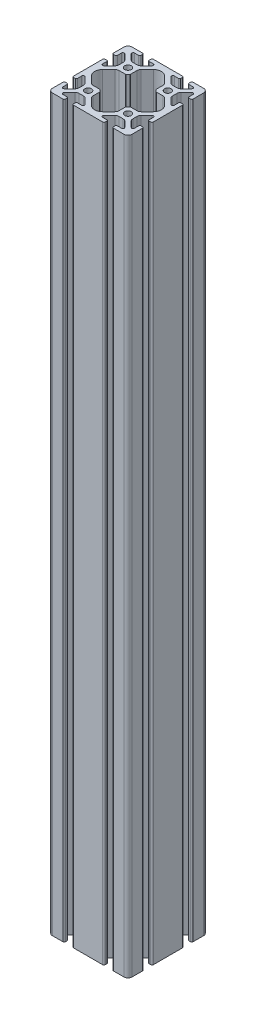
from build123d import *

# Parameters (mm, degrees)
SCHIZZO1_R                   = 2.5
ESTRUSIONE_ESTRUSIONE1_DEPTH = 550


with BuildPart() as part:
    # Schizzo1 → Estrusione-Estrusione1 (new body)
    with BuildSketch(Plane.XZ.offset(10)):
        with BuildLine():
            Line((11.9, 27.8), (11.9, 29))
            ThreePointArc((11.9, 29), (11.607106781, 29.707106781), (10.9, 30))
            Line((10.9, 30), (-10.9, 30))
            ThreePointArc((-10.9, 30), (-11.607106781, 29.707106781), (-11.9, 29))
            Line((-11.9, 29), (-11.9, 27.8))
            ThreePointArc((-11.9, 27.8), (-11.665685425, 27.234314575), (-11.1, 27))
            Line((-11.1, 27), (-7.872361109, 27))
            ThreePointArc((-7.872361109, 27), (-6.927822606, 26.36887955), (-7.149442636, 25.25472042))
            Line((-7.149442636, 25.25472042), (-11.275483397, 21.128679659))
            ThreePointArc((-11.275483397, 21.128679659), (-12.248753443, 20.478361405), (-13.39680374, 20.250000003))
            Line((-13.39680374, 20.250000003), (-16.603196261, 20.250000003))
            ThreePointArc((-16.603196261, 20.250000003), (-17.751246557, 20.478361405), (-18.724516603, 21.128679659))
            Line((-18.724516603, 21.128679659), (-22.850557363, 25.254720419))
            ThreePointArc((-22.850557363, 25.254720419), (-23.072177393, 26.368879549), (-22.12763889, 27))
            Line((-22.12763889, 27), (-18.9, 27))
            ThreePointArc((-18.9, 27), (-18.334314575, 27.234314575), (-18.1, 27.8))
            Line((-18.1, 27.8), (-18.1, 29))
            ThreePointArc((-18.1, 29), (-18.392893219, 29.707106781), (-19.1, 30))
            Line((-19.1, 30), (-27, 30))
            ThreePointArc((-27, 30), (-29.121320344, 29.121320344), (-30, 27))
            Line((-30, 27), (-30, 19.1))
            ThreePointArc((-30, 19.1), (-29.707106781, 18.392893219), (-29, 18.1))
            Line((-29, 18.1), (-27.8, 18.1))
            ThreePointArc((-27.8, 18.1), (-27.234314575, 18.334314575), (-27, 18.9))
            Line((-27, 18.9), (-27, 22.12763889))
            ThreePointArc((-27, 22.12763889), (-26.36887955, 23.072177392), (-25.254720421, 22.850557362))
            Line((-25.254720421, 22.850557362), (-21.128679659, 18.7245166))
            ThreePointArc((-21.128679659, 18.7245166), (-20.478361405, 17.751246554), (-20.250000003, 16.603196257))
            Line((-20.250000003, 16.603196257), (-20.250000003, 13.396803739))
            ThreePointArc((-20.250000003, 13.396803739), (-20.478361405, 12.248753443), (-21.128679659, 11.275483397))
            Line((-21.128679659, 11.275483397), (-25.254720419, 7.149442637))
            ThreePointArc((-25.254720419, 7.149442637), (-26.36887955, 6.927822607), (-27, 7.87236111))
            Line((-27, 7.87236111), (-27, 11.1))
            ThreePointArc((-27, 11.1), (-27.234314575, 11.665685425), (-27.8, 11.9))
            Line((-27.8, 11.9), (-29, 11.9))
            ThreePointArc((-29, 11.9), (-29.707106781, 11.607106781), (-30, 10.9))
            Line((-30, 10.9), (-30, -10.9))
            ThreePointArc((-30, -10.9), (-29.707106781, -11.607106781), (-29, -11.9))
            Line((-29, -11.9), (-27.8, -11.9))
            ThreePointArc((-27.8, -11.9), (-27.234314575, -11.665685425), (-27, -11.1))
            Line((-27, -11.1), (-27, -7.87236111))
            ThreePointArc((-27, -7.87236111), (-26.36887955, -6.927822608), (-25.254720421, -7.149442638))
            Line((-25.254720421, -7.149442638), (-21.128679659, -11.2754834))
            ThreePointArc((-21.128679659, -11.2754834), (-20.478361405, -12.248753446), (-20.250000003, -13.396803743))
            Line((-20.250000003, -13.396803743), (-20.250000003, -16.603196261))
            ThreePointArc((-20.250000003, -16.603196261), (-20.478361405, -17.751246557), (-21.128679659, -18.724516603))
            Line((-21.128679659, -18.724516603), (-25.254720419, -22.850557363))
            ThreePointArc((-25.254720419, -22.850557363), (-26.36887955, -23.072177393), (-27, -22.12763889))
            Line((-27, -22.12763889), (-27, -18.9))
            ThreePointArc((-27, -18.9), (-27.234314575, -18.334314575), (-27.8, -18.1))
            Line((-27.8, -18.1), (-29, -18.1))
            ThreePointArc((-29, -18.1), (-29.707106781, -18.392893219), (-30, -19.1))
            Line((-30, -19.1), (-30, -27))
            ThreePointArc((-30, -27), (-29.121320344, -29.121320344), (-27, -30))
            Line((-27, -30), (-19.1, -30))
            ThreePointArc((-19.1, -30), (-18.392893219, -29.707106781), (-18.1, -29))
            Line((-18.1, -29), (-18.1, -27.8))
            ThreePointArc((-18.1, -27.8), (-18.334314575, -27.234314575), (-18.9, -27))
            Line((-18.9, -27), (-22.12763889, -27))
            ThreePointArc((-22.12763889, -27), (-23.072177392, -26.36887955), (-22.850557362, -25.254720421))
            Line((-22.850557362, -25.254720421), (-18.724516602, -21.128679661))
            ThreePointArc((-18.724516602, -21.128679661), (-17.751246556, -20.478361407), (-16.603196259, -20.250000005))
            Line((-16.603196259, -20.250000005), (-13.39680374, -20.250000005))
            ThreePointArc((-13.39680374, -20.250000005), (-12.248753444, -20.478361407), (-11.275483399, -21.12867966))
            Line((-11.275483399, -21.12867966), (-7.14944264, -25.254720419))
            ThreePointArc((-7.14944264, -25.254720419), (-6.92782261, -26.36887955), (-7.872361112, -27))
            Line((-7.872361112, -27), (-11.1, -27))
            ThreePointArc((-11.1, -27), (-11.665685425, -27.234314575), (-11.9, -27.8))
            Line((-11.9, -27.8), (-11.9, -29))
            ThreePointArc((-11.9, -29), (-11.607106781, -29.707106781), (-10.9, -30))
            Line((-10.9, -30), (10.9, -30))
            ThreePointArc((10.9, -30), (11.607106781, -29.707106781), (11.9, -29))
            Line((11.9, -29), (11.9, -27.8))
            ThreePointArc((11.9, -27.8), (11.665685425, -27.234314575), (11.1, -27))
            Line((11.1, -27), (7.87236111, -27))
            ThreePointArc((7.87236111, -27), (6.927822608, -26.36887955), (7.149442638, -25.254720421))
            Line((7.149442638, -25.254720421), (11.275483398, -21.128679661))
            ThreePointArc((11.275483398, -21.128679661), (12.248753444, -20.478361407), (13.396803741, -20.250000005))
            Line((13.396803741, -20.250000005), (16.60319626, -20.250000005))
            ThreePointArc((16.60319626, -20.250000005), (17.751246556, -20.478361407), (18.724516601, -21.12867966))
            Line((18.724516601, -21.12867966), (22.85055736, -25.254720419))
            ThreePointArc((22.85055736, -25.254720419), (23.07217739, -26.36887955), (22.127638888, -27))
            Line((22.127638888, -27), (18.9, -27))
            ThreePointArc((18.9, -27), (18.334314575, -27.234314575), (18.1, -27.8))
            Line((18.1, -27.8), (18.1, -29))
            ThreePointArc((18.1, -29), (18.392893219, -29.707106781), (19.1, -30))
            Line((19.1, -30), (27, -30))
            ThreePointArc((27, -30), (29.121320344, -29.121320344), (30, -27))
            Line((30, -27), (30, -19.1))
            ThreePointArc((30, -19.1), (29.707106781, -18.392893219), (29, -18.1))
            Line((29, -18.1), (27.799999997, -18.1))
            ThreePointArc((27.799999997, -18.1), (27.234314572, -18.334314575), (26.999999996, -18.9))
            Line((26.999999996, -18.9), (26.999999996, -22.12763889))
            ThreePointArc((26.999999996, -22.12763889), (26.368879547, -23.072177392), (25.254720417, -22.850557361))
            Line((25.254720417, -22.850557361), (21.128679657, -18.724516601))
            ThreePointArc((21.128679657, -18.724516601), (20.478361404, -17.751246555), (20.250000001, -16.603196259))
            Line((20.250000001, -16.603196259), (20.250000001, -13.396803744))
            ThreePointArc((20.250000001, -13.396803744), (20.478361403, -12.248753448), (21.128679657, -11.275483402))
            Line((21.128679657, -11.275483402), (25.254720417, -7.149442642))
            ThreePointArc((25.254720417, -7.149442642), (26.368879547, -6.927822612), (26.999999996, -7.872361114))
            Line((26.999999996, -7.872361114), (26.999999996, -11.1))
            ThreePointArc((26.999999996, -11.1), (27.234314572, -11.665685425), (27.799999997, -11.9))
            Line((27.799999997, -11.9), (29, -11.9))
            ThreePointArc((29, -11.9), (29.707106781, -11.607106781), (30, -10.9))
            Line((30, -10.9), (30, 10.9))
            ThreePointArc((30, 10.9), (29.707106781, 11.607106781), (29, 11.9))
            Line((29, 11.9), (27.799999997, 11.9))
            ThreePointArc((27.799999997, 11.9), (27.234314572, 11.665685425), (26.999999996, 11.1))
            Line((26.999999996, 11.1), (26.999999996, 7.87236111))
            ThreePointArc((26.999999996, 7.87236111), (26.368879547, 6.927822608), (25.254720417, 7.149442639))
            Line((25.254720417, 7.149442639), (21.128679657, 11.275483399))
            ThreePointArc((21.128679657, 11.275483399), (20.478361404, 12.248753445), (20.250000001, 13.396803741))
            Line((20.250000001, 13.396803741), (20.250000001, 16.603196256))
            ThreePointArc((20.250000001, 16.603196256), (20.478361403, 17.751246552), (21.128679657, 18.724516598))
            Line((21.128679657, 18.724516598), (25.254720417, 22.850557358))
            ThreePointArc((25.254720417, 22.850557358), (26.368879547, 23.072177388), (26.999999996, 22.127638886))
            Line((26.999999996, 22.127638886), (26.999999996, 18.9))
            ThreePointArc((26.999999996, 18.9), (27.234314572, 18.334314575), (27.799999997, 18.1))
            Line((27.799999997, 18.1), (29, 18.1))
            ThreePointArc((29, 18.1), (29.707106781, 18.392893219), (30, 19.1))
            Line((30, 19.1), (30, 27))
            ThreePointArc((30, 27), (29.121320344, 29.121320344), (27, 30))
            Line((27, 30), (19.1, 30))
            ThreePointArc((19.1, 30), (18.392893219, 29.707106781), (18.1, 29))
            Line((18.1, 29), (18.1, 27.8))
            ThreePointArc((18.1, 27.8), (18.334314575, 27.234314575), (18.9, 27))
            Line((18.9, 27), (22.127638891, 27))
            ThreePointArc((22.127638891, 27), (23.072177394, 26.36887955), (22.850557364, 25.25472042))
            Line((22.850557364, 25.25472042), (18.724516603, 21.128679659))
            ThreePointArc((18.724516603, 21.128679659), (17.751246557, 20.478361405), (16.60319626, 20.250000003))
            Line((16.60319626, 20.250000003), (13.396803739, 20.250000003))
            ThreePointArc((13.396803739, 20.250000003), (12.248753443, 20.478361405), (11.275483397, 21.128679659))
            Line((11.275483397, 21.128679659), (7.149442637, 25.254720419))
            ThreePointArc((7.149442637, 25.254720419), (6.927822607, 26.368879549), (7.87236111, 27))
            Line((7.87236111, 27), (11.1, 27))
            ThreePointArc((11.1, 27), (11.665685425, 27.234314575), (11.9, 27.8))
        make_face()
        with Locations((-15, -15)):
            Circle(SCHIZZO1_R, mode=Mode.SUBTRACT)
        with Locations((15, -15)):
            Circle(SCHIZZO1_R, mode=Mode.SUBTRACT)
        with Locations((15, 15)):
            Circle(SCHIZZO1_R, mode=Mode.SUBTRACT)
        with Locations((-15, 15)):
            Circle(SCHIZZO1_R, mode=Mode.SUBTRACT)
        with BuildLine():
            Line((-4.242640695, -23.353196225), (-8.871320331, -18.724516589))
            ThreePointArc((-8.871320331, -18.724516589), (-9.521638584, -17.751246543), (-9.749999987, -16.603196247))
            Line((-9.749999987, -16.603196247), (-9.749999987, -11.670310206))
            ThreePointArc((-9.749999987, -11.670310206), (-9.788060221, -11.47896849), (-9.896446596, -11.316756816))
            Line((-9.896446596, -11.316756816), (-11.316756816, -9.896446596))
            ThreePointArc((-11.316756816, -9.896446596), (-11.47896849, -9.78806022), (-11.670310206, -9.749999986))
            Line((-11.670310206, -9.749999986), (-16.603196246, -9.749999986))
            ThreePointArc((-16.603196246, -9.749999986), (-17.751246544, -9.521638584), (-18.72451659, -8.87132033))
            Line((-18.72451659, -8.87132033), (-23.353196265, -4.242640655))
            ThreePointArc((-23.353196265, -4.242640655), (-25.110555577, 3e-08), (-23.353196265, 4.242640715))
            Line((-23.353196265, 4.242640715), (-18.724516625, 8.871320355))
            ThreePointArc((-18.724516625, 8.871320355), (-17.751246578, 9.521638609), (-16.60319628, 9.750000012))
            Line((-16.60319628, 9.750000012), (-11.67031024, 9.750000012))
            ThreePointArc((-11.67031024, 9.750000012), (-11.478968524, 9.788060246), (-11.31675685, 9.896446621))
            Line((-11.31675685, 9.896446621), (-9.896446596, 11.316756875))
            ThreePointArc((-9.896446596, 11.316756875), (-9.788060221, 11.478968549), (-9.749999987, 11.670310265))
            Line((-9.749999987, 11.670310265), (-9.749999987, 16.603196306))
            ThreePointArc((-9.749999987, 16.603196306), (-9.521638584, 17.751246603), (-8.87132033, 18.72451665))
            Line((-8.87132033, 18.72451665), (-4.24264069, 23.35319629))
            ThreePointArc((-4.24264069, 23.35319629), (-5e-09, 25.110555602), (4.24264068, 23.35319629))
            Line((4.24264068, 23.35319629), (8.87132035, 18.72451662))
            ThreePointArc((8.87132035, 18.72451662), (9.521638604, 17.751246573), (9.750000006, 16.603196276))
            Line((9.750000006, 16.603196276), (9.750000006, 11.670310264))
            ThreePointArc((9.750000006, 11.670310264), (9.78806024, 11.478968547), (9.896446616, 11.316756873))
            Line((9.896446616, 11.316756873), (11.316756868, 9.896446621))
            ThreePointArc((11.316756868, 9.896446621), (11.478968542, 9.788060246), (11.670310258, 9.750000012))
            Line((11.670310258, 9.750000012), (16.603196271, 9.750000012))
            ThreePointArc((16.603196271, 9.750000012), (17.751246568, 9.521638609), (18.724516615, 8.871320355))
            Line((18.724516615, 8.871320355), (23.35319625, 4.24264072))
            ThreePointArc((23.35319625, 4.24264072), (25.110555562, 3.5e-08), (23.35319625, -4.24264065))
            Line((23.35319625, -4.24264065), (18.72451657, -8.87132033))
            ThreePointArc((18.72451657, -8.87132033), (17.751246523, -9.521638584), (16.603196226, -9.749999986))
            Line((16.603196226, -9.749999986), (11.670310187, -9.749999986))
            ThreePointArc((11.670310187, -9.749999986), (11.47896847, -9.78806022), (11.316756796, -9.896446596))
            Line((11.316756796, -9.896446596), (9.896446616, -11.316756776))
            ThreePointArc((9.896446616, -11.316756776), (9.78806024, -11.47896845), (9.750000006, -11.670310166))
            Line((9.750000006, -11.670310166), (9.750000006, -16.603196206))
            ThreePointArc((9.750000006, -16.603196206), (9.521638604, -17.751246504), (8.87132035, -18.72451655))
            Line((8.87132035, -18.72451655), (4.242640675, -23.353196225))
            ThreePointArc((4.242640675, -23.353196225), (-1e-08, -25.110555537), (-4.242640695, -23.353196225))
        make_face(mode=Mode.SUBTRACT)
    extrude(amount=-ESTRUSIONE_ESTRUSIONE1_DEPTH)


solid = part.part
